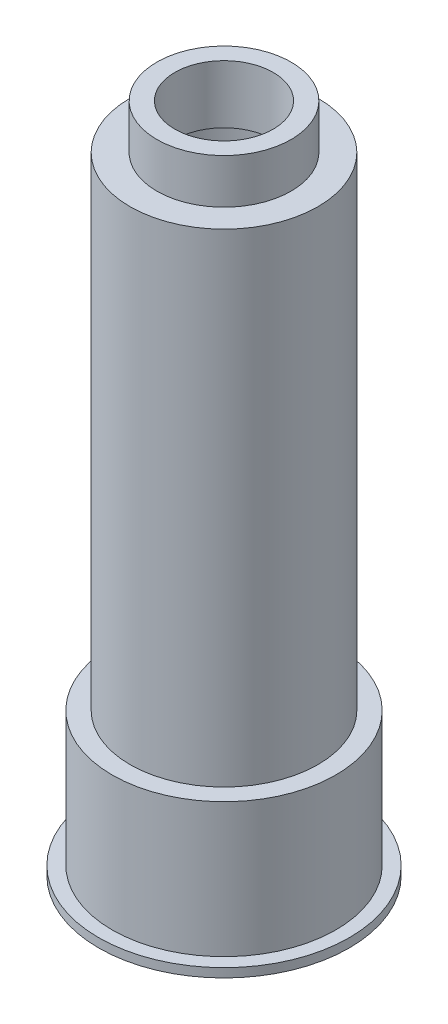
from build123d import *

# Parameters (mm, degrees)
SKETCH1_R      = 14
SKETCH1_R_2    = 12.5
EXTRUDE1_DEPTH = 1
SKETCH2_R      = 12.5
SKETCH2_R_2    = 10.5
EXTRUDE2_DEPTH = 15
SKETCH4_R      = 10.5
SKETCH4_R_2    = 8.5
EXTRUDE3_DEPTH = 55.5
SKETCH7_R      = 8.5
SKETCH7_R_2    = 5.5
EXTRUDE6_DEPTH = 1.5
SKETCH8_R      = 7.5
SKETCH8_R_2    = 5.5
EXTRUDE7_DEPTH = 5


with BuildPart() as part:
    # Sketch1 → Extrude1 (new body)
    with BuildSketch(Plane(origin=(0, 0, 0), x_dir=(1, 0, 0), z_dir=(0, 1, 0))):
        Circle(SKETCH1_R)
        Circle(SKETCH1_R_2, mode=Mode.SUBTRACT)
    extrude(amount=EXTRUDE1_DEPTH)


with BuildPart() as body_2:
    # Sketch2 → Extrude2 (new body)
    with BuildSketch(Plane(origin=(0, 1, 0), x_dir=(-1, 0, 0), z_dir=(0, 1, 0))):
        Circle(SKETCH2_R)
        Circle(SKETCH2_R_2, mode=Mode.SUBTRACT)
    extrude(amount=EXTRUDE2_DEPTH)

    # Sketch4 → Extrude3 (add)
    with BuildSketch(Plane(origin=(0, 14.5, 0), x_dir=(-1, 0, 0), z_dir=(0, 1, 0))):
        Circle(SKETCH4_R)
        Circle(SKETCH4_R_2, mode=Mode.SUBTRACT)
    extrude(amount=EXTRUDE3_DEPTH)

    # Sketch7 → Extrude6 (add)
    with BuildSketch(Plane(origin=(0, 68.5, 0), x_dir=(-1, 0, 0), z_dir=(0, 1, 0))):
        Circle(SKETCH7_R)
        Circle(SKETCH7_R_2, mode=Mode.SUBTRACT)
    extrude(amount=EXTRUDE6_DEPTH)

    # Sketch8 → Extrude7 (add)
    with BuildSketch(Plane(origin=(0, 70, 0), x_dir=(-1, 0, 0), z_dir=(0, 1, 0))):
        Circle(SKETCH8_R)
        Circle(SKETCH8_R_2, mode=Mode.SUBTRACT)
    extrude(amount=EXTRUDE7_DEPTH)


solid = Compound([part.part, body_2.part])
